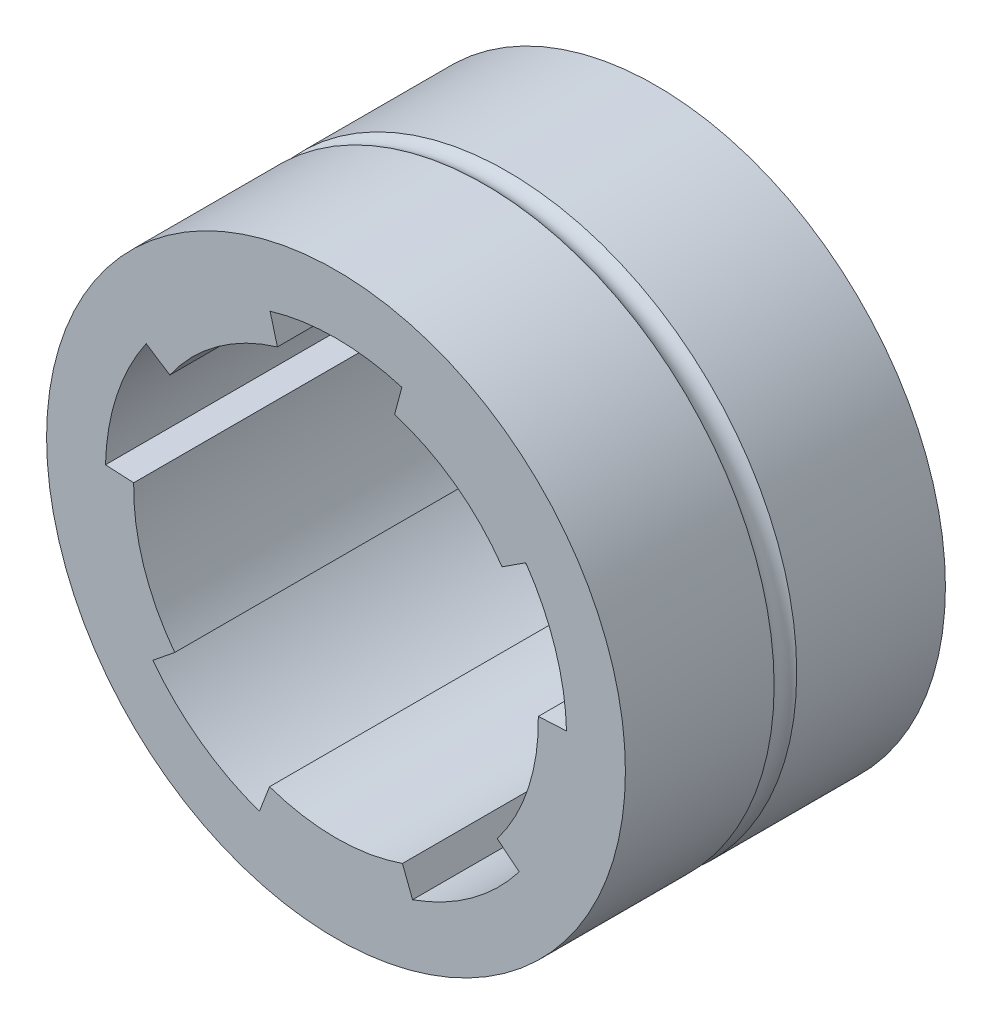
from build123d import *

# Parameters (mm, degrees)
SKETCH1_R           = 30.75
BOSS_EXTRUDE1_DEPTH = 34


with BuildPart() as part:
    # Sketch1 → Boss-Extrude1 (new body)
    with BuildSketch(Plane.XY):
        Circle(SKETCH1_R)
        with BuildLine():
            Line((-17.649126209, 12.27836895), (-20.165137913, 13.912286055))
            ThreePointArc((-20.165137913, 13.912286055), (-23.299613116, 7.570503216), (-24.491375834, 0.597494827))
            Line((-24.491375834, 0.597494827), (-21.49548723, 0.440486958))
            ThreePointArc((-21.49548723, 0.440486958), (-20.4477151, -6.643865379), (-17.131302733, -12.991091819))
            Line((-17.131302733, -12.991091819), (-19.462740618, -14.879052992))
            ThreePointArc((-19.462740618, -14.879052992), (-14.39995283, -19.819834732), (-8.136502697, -23.108046524))
            Line((-8.136502697, -23.108046524), (-7.061398848, -20.307305245))
            ThreePointArc((-7.061398848, -20.307305245), (0, -21.5), (7.061398848, -20.307305245))
            Line((7.061398848, -20.307305245), (8.136502697, -23.108046524))
            ThreePointArc((8.136502697, -23.108046524), (14.39995283, -19.819834732), (19.462740618, -14.879052992))
            Line((19.462740618, -14.879052992), (17.131302733, -12.991091819))
            ThreePointArc((17.131302733, -12.991091819), (20.4477151, -6.643865379), (21.49548723, 0.440486958))
            Line((21.49548723, 0.440486958), (24.491375834, 0.597494827))
            ThreePointArc((24.491375834, 0.597494827), (23.299613116, 7.570503216), (20.165137913, 13.912286055))
            Line((20.165137913, 13.912286055), (17.649126209, 12.27836895))
            ThreePointArc((17.649126209, 12.27836895), (12.637382924, 17.393865379), (6.223542865, 20.579541156))
            Line((6.223542865, 20.579541156), (7, 23.477318635))
            ThreePointArc((7, 23.477318635), (0, 24.498663031), (-7, 23.477318635))
            Line((-7, 23.477318635), (-6.223542865, 20.579541156))
            ThreePointArc((-6.223542865, 20.579541156), (-12.637382924, 17.393865379), (-17.649126209, 12.27836895))
        make_face(mode=Mode.SUBTRACT)
    extrude(amount=-BOSS_EXTRUDE1_DEPTH)

    # Sketch2 → Cut-Revolve1 (revolve, cut)
    with BuildSketch(Plane.ZY):
        with BuildLine():
            Line((-18.2, 30.75), (-15.8, 30.75))
            ThreePointArc((-15.8, 30.75), (-17, 30.25), (-18.2, 30.75))
        make_face()
    revolve(axis=Axis((0, 0, 27.953503857), (0, 0, -1)), mode=Mode.SUBTRACT)


solid = part.part
